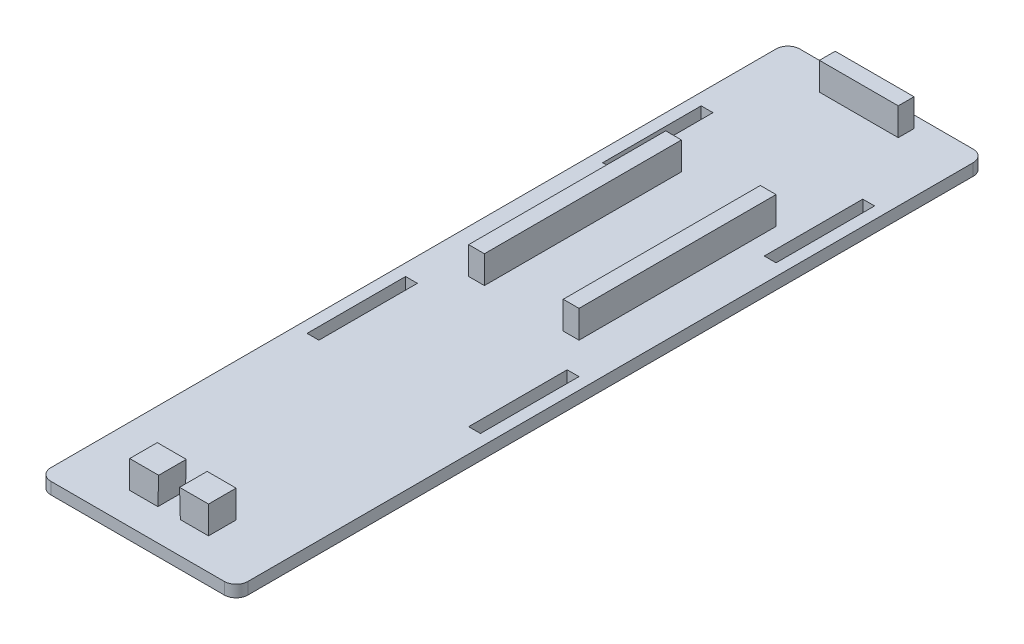
from build123d import *

# Parameters (mm, degrees)
SKETCH1_W           = 50
SKETCH1_H           = 190
BOSS_EXTRUDE1_DEPTH = 3
FILLET1_R           = 3
SKETCH2_W           = 20
SKETCH2_H           = 4
SKETCH2_W_2         = 4
SKETCH2_H_2         = 50
BOSS_EXTRUDE2_DEPTH = 7
SKETCH3_W           = 20
SKETCH3_H           = 7
BOSS_EXTRUDE3_DEPTH = 7
CUT_EXTRUDE1_DEPTH  = 7
SKETCH6_W           = 3
SKETCH6_H           = 25
CUT_EXTRUDE2_DEPTH  = 7


with BuildPart() as part:
    # Sketch1 → Boss-Extrude1 (new body)
    with BuildSketch(Plane(origin=(0, 0, 0), x_dir=(1, 0, 0), z_dir=(0, 1, 0))):
        with Locations((25, 95)):
            Rectangle(SKETCH1_W, SKETCH1_H)
    extrude(amount=BOSS_EXTRUDE1_DEPTH)

    # Fillet1
    fillet1_edges = [part.edges().sort_by_distance(p)[0] for p in [
        (0, 1.5, -190),
        (50, 1.5, -190),
        (50, 1.5, 0),
        (0, 1.5, 0),
    ]]
    fillet(fillet1_edges, radius=FILLET1_R)

    # Sketch2 → Boss-Extrude2 (add)
    with BuildSketch(Plane(origin=(0, 3, 0), x_dir=(1, 0, 0), z_dir=(0, 1, 0))):
        with Locations((25, 185)):
            Rectangle(SKETCH2_W, SKETCH2_H)
        with Locations((13, 123)):
            Rectangle(SKETCH2_W_2, SKETCH2_H_2)
        with Locations((37, 123)):
            Rectangle(SKETCH2_W_2, SKETCH2_H_2)
    extrude(amount=BOSS_EXTRUDE2_DEPTH)

    # Sketch3 → Boss-Extrude3 (add)
    with BuildSketch(Plane(origin=(0, 3, 0), x_dir=(1, 0, 0), z_dir=(0, 1, 0))):
        with Locations((25, 11.5)):
            Rectangle(SKETCH3_W, SKETCH3_H)
    extrude(amount=BOSS_EXTRUDE3_DEPTH)

    # Sketch5 → Cut-Extrude1 (cut)
    with BuildSketch(Plane(origin=(0, 0, -15), x_dir=(-1, 0, 0), z_dir=(0, 0, -1))):
        Polygon((-22.15, 3), (-22.35, 10), (-27.65, 10), (-27.85, 3), align=None)
    extrude(amount=-CUT_EXTRUDE1_DEPTH, mode=Mode.SUBTRACT)

    # Sketch6 → Cut-Extrude2 (cut)
    with BuildSketch(Plane(origin=(0, 3, 0), x_dir=(1, 0, 0), z_dir=(0, 1, 0))):
        with Locations((4.5, 152.5)):
            Rectangle(SKETCH6_W, SKETCH6_H)
        with Locations((45.5, 152.5)):
            Rectangle(SKETCH6_W, SKETCH6_H)
        with Locations((4.5, 77.5)):
            Rectangle(SKETCH6_W, SKETCH6_H)
        with Locations((45.5, 77.5)):
            Rectangle(SKETCH6_W, SKETCH6_H)
    extrude(amount=-CUT_EXTRUDE2_DEPTH, mode=Mode.SUBTRACT)


solid = part.part
